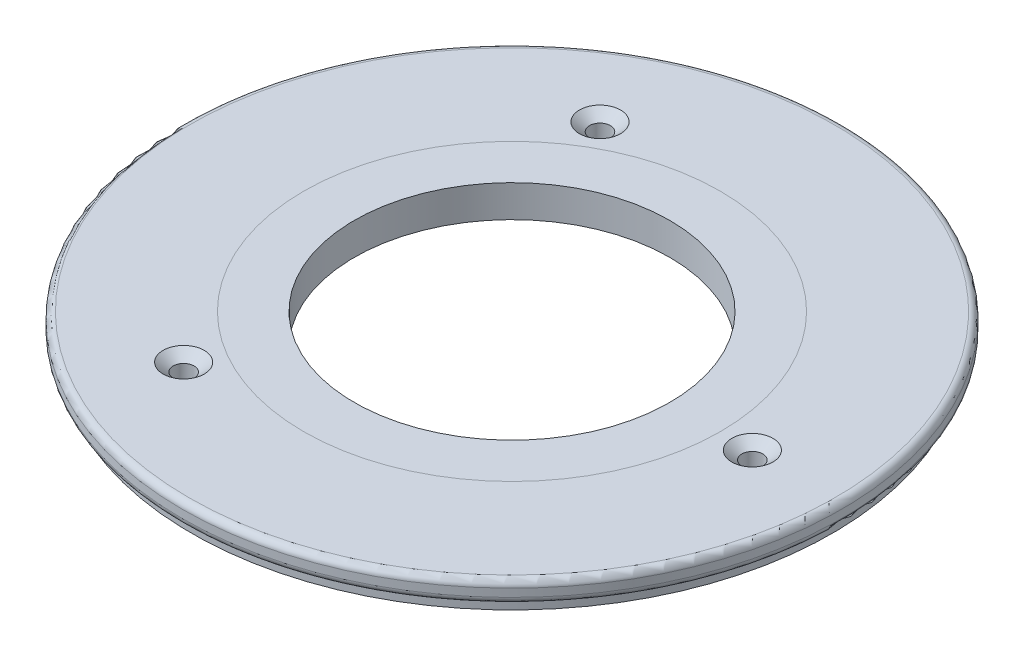
from build123d import *

# Parameters (mm, degrees)
SKETCH1_R                                          = 78.359
SKETCH1_R_2                                        = 37.5031
BOSS_EXTRUDE1_DEPTH                                = 7.62
CSK_FOR_10_FLAT_HEAD_MACHINE_SCREW_100_D           = 4.9784
CSK_FOR_10_FLAT_HEAD_MACHINE_SCREW_100_CSINK_D     = 9.779
CSK_FOR_10_FLAT_HEAD_MACHINE_SCREW_100_CSINK_ANGLE = 100
CIRPATTERN1_COUNT                                  = 3
SKETCH6_R                                          = 78.359
SKETCH6_R_2                                        = 76.1746
CUT_EXTRUDE1_DEPTH                                 = 2.54
FILLET1_R                                          = 1.5875


with BuildPart() as part:
    # Sketch1 → Boss-Extrude1 (new body)
    with BuildSketch(Plane(origin=(0, 0, 0), x_dir=(1, 0, 0), z_dir=(0, 1, 0))):
        with Locations(Location((0, 0, 0), (0, 0, 90))):
            Circle(SKETCH1_R)
        with Locations(Location((0, 0, 0), (0, 0, 90))):
            Circle(SKETCH1_R_2, mode=Mode.SUBTRACT)
    extrude(amount=BOSS_EXTRUDE1_DEPTH)

    # CSK for #10 Flat Head Machine Screw (100)1 (through all)
    with Locations(Plane(origin=(0, 7.62, 0), x_dir=(1, 0, 0), z_dir=(0, 1, 0))):
        with Locations((57.15, 0)):
            csk_for_10_flat_head_machine_screw_100 = CounterSinkHole(CSK_FOR_10_FLAT_HEAD_MACHINE_SCREW_100_D / 2, CSK_FOR_10_FLAT_HEAD_MACHINE_SCREW_100_CSINK_D / 2, counter_sink_angle=CSK_FOR_10_FLAT_HEAD_MACHINE_SCREW_100_CSINK_ANGLE)

    # CirPattern1: CSK for #10 Flat Head Machine Screw (100)1 ×3 about axis
    cirpattern1_axis = Axis((0, 0, 0), (0, 1, 0))
    for i in range(1, CIRPATTERN1_COUNT):
        add(csk_for_10_flat_head_machine_screw_100.rotate(cirpattern1_axis, i * 360 / CIRPATTERN1_COUNT), mode=Mode.SUBTRACT)

    # Sketch6 → Cut-Extrude1 (cut)
    with BuildSketch(Plane.XZ):
        with Locations(Location((0, 0, 0), (0, 0, 270))):
            Circle(SKETCH6_R)
        with Locations(Location((0, 0, 0), (0, 0, 270))):
            Circle(SKETCH6_R_2, mode=Mode.SUBTRACT)
    extrude(amount=-CUT_EXTRUDE1_DEPTH, mode=Mode.SUBTRACT)

    # Fillet1
    fillet1_edges = [part.edges().sort_by_distance(p)[0] for p in [
        (0, 2.54, 78.359),
        (0, 7.62, 78.359),
    ]]
    fillet(fillet1_edges, radius=FILLET1_R)


solid = part.part
